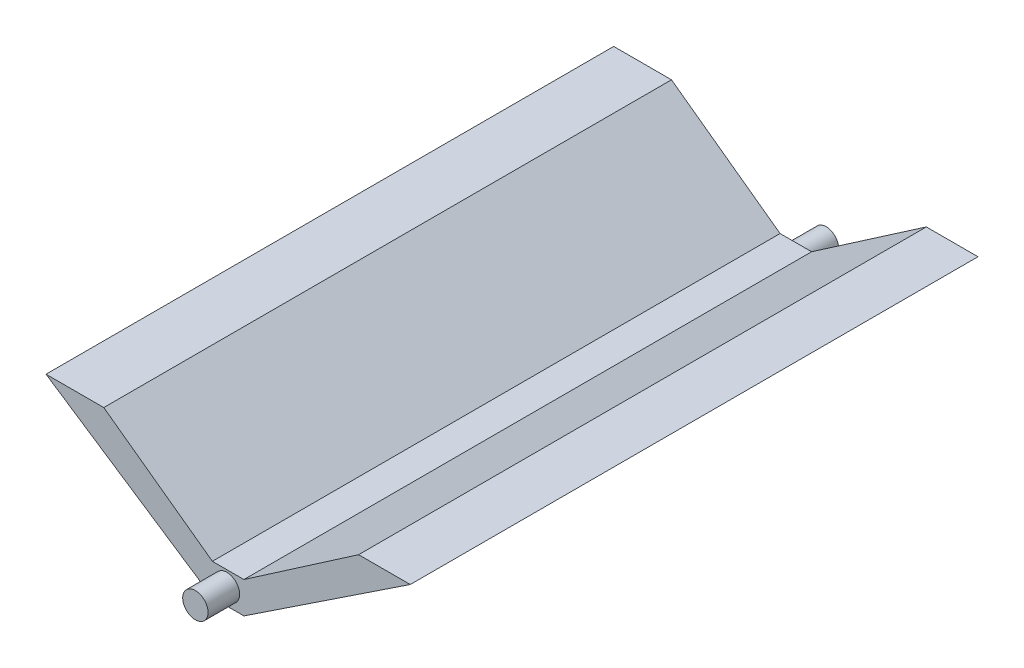
from build123d import *

# Parameters (mm, degrees)
BOSS_EXTRUDE1_DEPTH = 360
CUT_EXTRUDE1_DEPTH  = 360
SKETCH3_R           = 8.05
BOSS_EXTRUDE2_DEPTH = 20
SKETCH4_R           = 7.873776935
BOSS_EXTRUDE3_DEPTH = 20


with BuildPart() as part:
    # Sketch1 → Boss-Extrude1 (new body)
    with BuildSketch(Plane.XY):
        Polygon((-115.5, 32.593599034), (-10, -37.406400966), (10, -37.406400966), (115.5, 32.593599034), align=None)
    extrude(amount=BOSS_EXTRUDE1_DEPTH)

    # Sketch2 → Cut-Extrude1 (cut)
    with BuildSketch(Plane.XY.offset(360)):
        Polygon((-78.867089656, 32.593599034), (82.733123463, 32.593599034), (10, -17.406400966), (-10, -17.406400966), align=None)
    extrude(amount=-CUT_EXTRUDE1_DEPTH, mode=Mode.SUBTRACT)

    # Sketch3 → Boss-Extrude2 (add)
    with BuildSketch(Plane.XY.offset(360)):
        with Locations((-0.773206761, -26.891281742)):
            Circle(SKETCH3_R)
    extrude(amount=BOSS_EXTRUDE2_DEPTH)

    # Sketch4 → Boss-Extrude3 (add)
    with BuildSketch(Plane(origin=(0, 0, 0), x_dir=(-1, 0, 0), z_dir=(0, 0, -1))):
        with Locations((0.773206761, -26.891281742)):
            Circle(SKETCH4_R)
    extrude(amount=BOSS_EXTRUDE3_DEPTH)


solid = part.part
